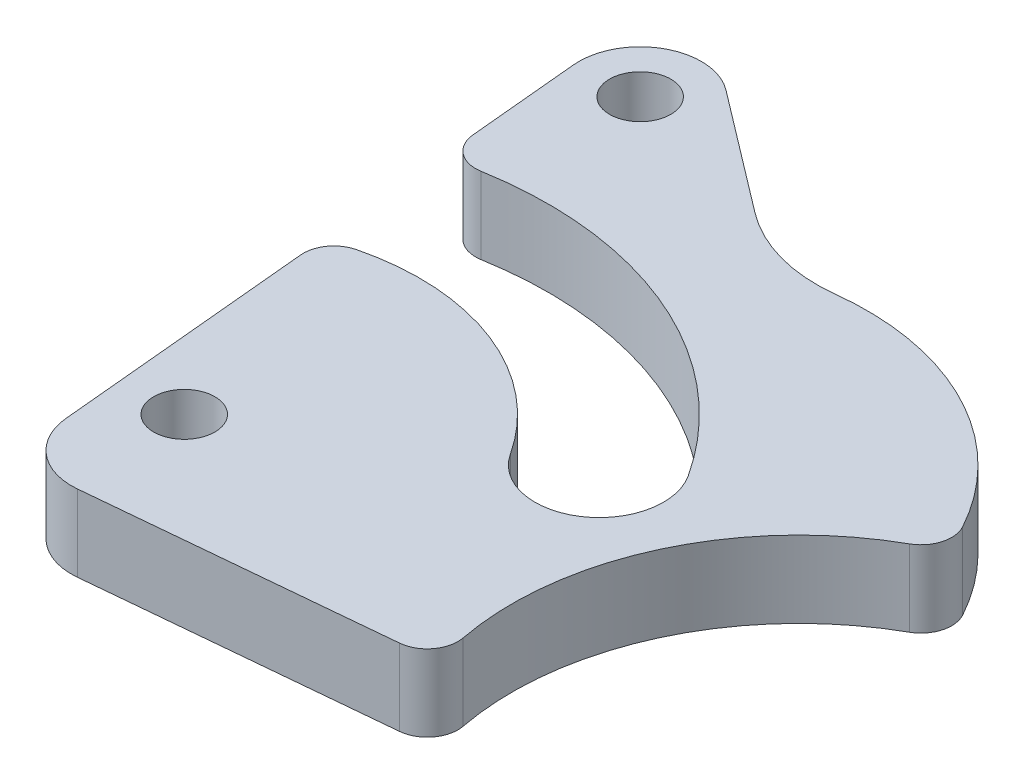
from build123d import *

# Parameters (mm, degrees)
SKETCH_1_R          = 2
EXTRUDE_1_DEPTH     = 5
EXTRUDE_2_DEPTH     = 5
CUT_EXTRUDE_1_DEPTH = 6
EXTRUDE_3_DEPTH     = 5
FILLET_1_R          = 10
FILLET_2_R          = 2
SKETCH_6_R          = 18.75
CUT_EXTRUDE_2_DEPTH = 6
FILLET_3_R          = 2


with BuildPart() as part:
    # 草图1 → 凸台-拉伸1 (new body)
    with BuildSketch(Plane(origin=(0, 0, 0), x_dir=(1, 0, 0), z_dir=(0, 1, 0))):
        with BuildLine():
            ThreePointArc((-20.0875, 4), (-23.044826598, 2.693365811), (-24.070081176, -0.372890305))
            ThreePointArc((-24.070081176, -0.372890305), (-22.780865811, -2.957326598), (-20.0875, -4))
            ThreePointArc((-20.0875, -4), (-17.130173402, -2.693365811), (-16.104918824, 0.372890305))
            Line((-16.104918824, 0.372890305), (-16.444526225, 4))
            Line((-16.444526225, 4), (-20.0875, 4))
        make_face()
        with Locations((-20.0875, 0)):
            Circle(SKETCH_1_R, mode=Mode.SUBTRACT)
        with BuildLine():
            Line((-27.14754486, 32.495352138), (-24.070081176, -0.372890305))
            ThreePointArc((-24.070081176, -0.372890305), (-23.044826598, 2.693365811), (-20.0875, 4))
            Line((-20.0875, 4), (-16.444526225, 4))
            Line((-16.444526225, 4), (-18.333300994, 24.172685504))
            Line((-18.333300994, 24.172685504), (-25.585127327, 29.683464909))
            ThreePointArc((-25.585127327, 29.683464909), (-26.661456606, 30.925425609), (-27.14754486, 32.495352138))
        make_face()
        with BuildLine():
            ThreePointArc((-20.74480004, 36.053019976), (-25.107780517, 36.364735365), (-27.14754486, 32.495352138))
            ThreePointArc((-27.14754486, 32.495352138), (-26.661456606, 30.925425609), (-25.585127327, 29.683464909))
            Line((-25.585127327, 29.683464909), (-18.333300994, 24.172685504))
            Line((-18.333300994, 24.172685504), (-19.182382508, 33.241132747))
            ThreePointArc((-19.182382508, 33.241132747), (-19.668470762, 34.811059276), (-20.74480004, 36.053019976))
        make_face()
        with Locations((-23.164963684, 32.868242443)):
            Circle(SKETCH_1_R, mode=Mode.SUBTRACT)
        with BuildLine():
            Line((22.507663644, 3.184777534), (-20.74480004, 36.053019976))
            ThreePointArc((-20.74480004, 36.053019976), (-19.668470762, 34.811059276), (-19.182382508, 33.241132747))
            Line((-19.182382508, 33.241132747), (-18.333300994, 24.172685504))
            Line((-18.333300994, 24.172685504), (8.212637649, 4))
            Line((8.212637649, 4), (20.0875, 4))
            ThreePointArc((20.0875, 4), (21.364388771, 3.790719598), (22.507663644, 3.184777534))
        make_face()
        with BuildLine():
            ThreePointArc((-16.104918824, 0.372890305), (-17.130173402, -2.693365811), (-20.0875, -4))
            Line((-20.0875, -4), (20.0875, -4))
            ThreePointArc((20.0875, -4), (18.810611229, -3.790719598), (17.667336356, -3.184777534))
            Line((17.667336356, -3.184777534), (8.212637649, 4))
            Line((8.212637649, 4), (-16.444526225, 4))
            Line((-16.444526225, 4), (-16.104918824, 0.372890305))
        make_face()
        with BuildLine():
            ThreePointArc((17.667336356, -3.184777534), (18.810611229, -3.790719598), (20.0875, -4))
            ThreePointArc((20.0875, -4), (23.878219598, -1.276888771), (22.507663644, 3.184777534))
            ThreePointArc((22.507663644, 3.184777534), (21.364388771, 3.790719598), (20.0875, 4))
            Line((20.0875, 4), (8.212637649, 4))
            Line((8.212637649, 4), (17.667336356, -3.184777534))
        make_face()
        with Locations((20.0875, 0)):
            Circle(SKETCH_1_R, mode=Mode.SUBTRACT)
        Polygon((-18.333300994, 24.172685504), (-16.444526225, 4), (8.212637649, 4), align=None)
    extrude(amount=EXTRUDE_1_DEPTH)

    # 草图2 → 凸台-拉伸2 (add)
    with BuildSketch(Plane(origin=(0, 5, 0), x_dir=(1, 0, 0), z_dir=(0, 1, 0))):
        with BuildLine():
            ThreePointArc((-20.0875, -4), (-22.780865811, -2.957326598), (-24.070081176, -0.372890305))
            Line((-24.070081176, -0.372890305), (-23.720962628, -4.10158193))
            ThreePointArc((-23.720962628, -4.10158193), (-22.290826699, -6.808468121), (-19.365512753, -7.711274824))
            Line((-19.365512753, -7.711274824), (20.460368699, -3.982583199))
            ThreePointArc((20.460368699, -3.982583199), (20.274137625, -3.995643427), (20.0875, -4))
            Line((20.0875, -4), (-20.0875, -4))
        make_face()
    extrude(amount=-EXTRUDE_2_DEPTH)

    # 草图3 → 切除-拉伸1 (cut, through all)
    with BuildSketch(Plane(origin=(0, 5, 0), x_dir=(1, 0, 0), z_dir=(0, 1, 0))):
        with BuildLine():
            ThreePointArc((-36.289327432, 17.433897667), (-37.629570165, 14.285674695), (-36.182704661, 11.185007239))
            ThreePointArc((-36.182704661, 11.185007239), (-31.653466249, 15.823666602), (-25.858788976, 18.731049718))
            Line((-25.858788976, 18.731049718), (-26.257218708, 22.986399698))
            ThreePointArc((-26.257218708, 22.986399698), (-31.612650276, 20.82332613), (-36.289327432, 17.433897667))
        make_face()
        with BuildLine():
            ThreePointArc((-25.858788976, 18.731049718), (-11.47348363, 17.605644606), (-1.756724615, 6.938492183))
            ThreePointArc((-1.756724615, 6.938492183), (0.40025314, 9.594618202), (-0.134776474, 12.974159854))
            ThreePointArc((-0.134776474, 12.974159854), (-11.569633945, 22.223545124), (-26.257218708, 22.986399698))
            Line((-26.257218708, 22.986399698), (-25.858788976, 18.731049718))
        make_face()
        with BuildLine():
            ThreePointArc((-7.176914189, 8.395044611), (-4.745829362, 6.62850376), (-1.756724615, 6.938492183))
            ThreePointArc((-1.756724615, 6.938492183), (-11.47348363, 17.605644606), (-25.858788976, 18.731049718))
            Line((-25.858788976, 18.731049718), (-25.456435977, 14.433798061))
            ThreePointArc((-25.456435977, 14.433798061), (-15.256790284, 14.622730376), (-7.176914189, 8.395044611))
        make_face()
        with BuildLine():
            ThreePointArc((-25.858788976, 18.731049718), (-31.653466249, 15.823666602), (-36.182704661, 11.185007239))
            ThreePointArc((-36.182704661, 11.185007239), (-33.358528619, 10.15793874), (-30.571035397, 11.280757314))
            ThreePointArc((-30.571035397, 11.280757314), (-28.168999159, 13.109133127), (-25.456435977, 14.433798061))
            Line((-25.456435977, 14.433798061), (-25.858788976, 18.731049718))
        make_face()
    extrude(amount=-CUT_EXTRUDE_1_DEPTH, mode=Mode.SUBTRACT)

    # 草图4 → 凸台-拉伸3 (add)
    with BuildSketch(Plane(origin=(0, 5, 0), x_dir=(1, 0, 0), z_dir=(0, 1, 0))):
        with BuildLine():
            ThreePointArc((13.821061528, 9.785866119), (13.838380431, 10.235085855), (13.844154668, 10.684602232))
            ThreePointArc((13.844154668, 10.684602232), (6.570974544, 24.885382325), (-9.202948787, 27.282181672))
            Line((-9.202948787, 27.282181672), (13.821061528, 9.785866119))
        make_face()
    extrude(amount=-EXTRUDE_3_DEPTH)

    # 圆角1
    fillet_1_edges = [part.edges().sort_by_distance(p)[0] for p in [
        (13.821061528, 2.5, -9.785866119),
        (-9.202948787, 2.5, -27.282181672),
    ]]
    fillet(fillet_1_edges, radius=FILLET_1_R)

    # 圆角2
    fillet_2_edges = [part.edges().sort_by_distance(p)[0] for p in [
        (-26.257218708, 2.5, -22.986399698),
        (-25.456435977, 2.5, -14.433798061),
    ]]
    fillet(fillet_2_edges, radius=FILLET_2_R)

    # 草图6 → 切除-拉伸2 (cut, through all)
    with BuildSketch(Plane(origin=(0, 5, 0), x_dir=(1, 0, 0), z_dir=(0, 1, 0))):
        with Locations((20.0875, 0)):
            Circle(SKETCH_6_R)
    extrude(amount=-CUT_EXTRUDE_2_DEPTH, mode=Mode.SUBTRACT)

    # 圆角3
    fillet_3_edges = [part.edges().sort_by_distance(p)[0] for p in [
        (12.591508983, 2.5, -17.186407963),
        (2.22176543, 2.5, 5.690169441),
    ]]
    fillet(fillet_3_edges, radius=FILLET_3_R)


solid = part.part
